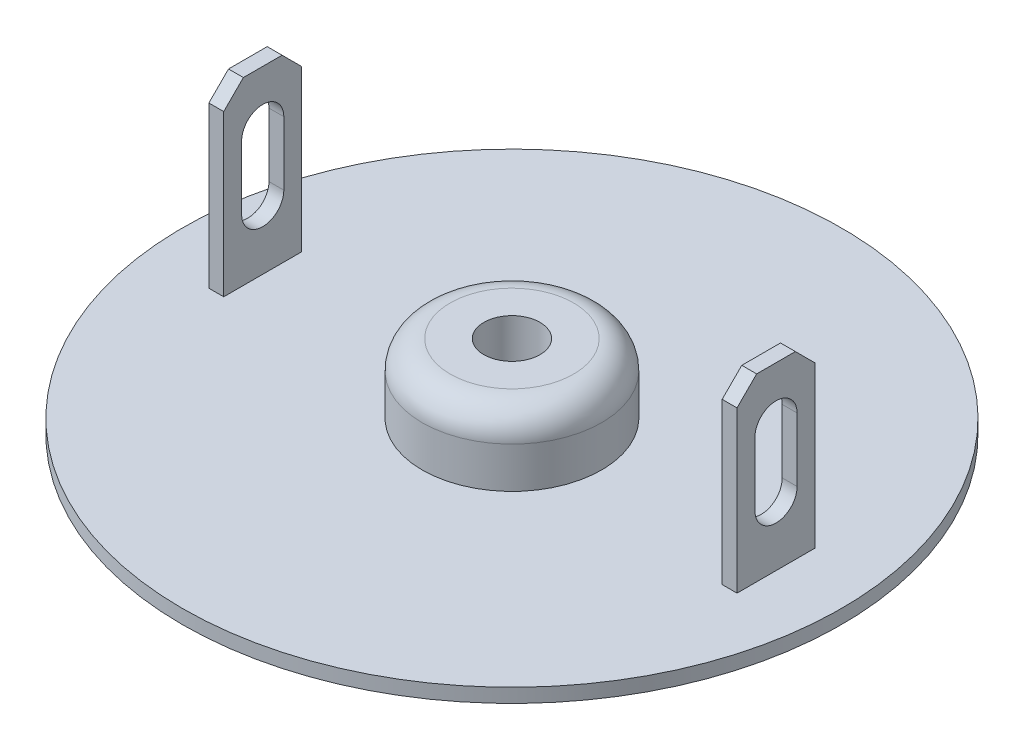
from build123d import *

# Parameters (mm, degrees)
SKETCH_1_R                 = 11.75
SKETCH_1_R_2               = 1
EXTRUDE_1_DEPTH            = 0.5
SKETCH_2_W                 = 0.53
SKETCH_2_H                 = 2.78
EXTRUDE_2_DEPTH            = 6.42
CHAMFER_1_SIZE             = 0.7
CUT_EXTRUDE_1_DEPTH        = 0.53
SKETCH_4_W                 = 2.2
SKETCH_4_H                 = 2.46
FILLET_1_R                 = 1
CHAMFER_1_OF_MIRROR_1_SIZE = 0.7


with BuildPart() as part:
    # 草图1 → 凸台-拉伸1 (new body)
    with BuildSketch(Plane(origin=(0, 0, 0), x_dir=(1, 0, 0), z_dir=(0, 1, 0))):
        Circle(SKETCH_1_R)
        Circle(SKETCH_1_R_2, mode=Mode.SUBTRACT)
    extrude(amount=EXTRUDE_1_DEPTH)

    # 草图2 → 凸台-拉伸2 (add)
    with BuildSketch(Plane(origin=(0, 0.5, 0), x_dir=(1, 0, 0), z_dir=(0, 1, 0))):
        with Locations((-9.15, 0)):
            Rectangle(SKETCH_2_W, SKETCH_2_H)
    extrude_2 = extrude(amount=EXTRUDE_2_DEPTH)

    # 倒角1
    chamfer_1_edges = [part.edges().sort_by_distance(p)[0] for p in [
        (-9.15, 6.92, -1.39),
        (-9.15, 6.92, 1.39),
    ]]
    chamfer(chamfer_1_edges, length=CHAMFER_1_SIZE)

    # 草图3 → 切除-拉伸1 (cut)
    with BuildSketch(Plane.ZY.offset(9.415)):
        with BuildLine():
            Line((0.751927557, 4.991992343), (0.751927557, 2.722407652))
            ThreePointArc((0.751927557, 2.722407652), (0, 1.970480095), (-0.751927557, 2.722407652))
            Line((-0.751927557, 2.722407652), (-0.751927557, 4.991992343))
            ThreePointArc((-0.751927557, 4.991992343), (0, 5.7439199), (0.751927557, 4.991992343))
        make_face()
    cut_extrude_1 = extrude(amount=-CUT_EXTRUDE_1_DEPTH, mode=Mode.SUBTRACT)

    # 草图4 → 旋转1 (revolve)
    with BuildSketch(Plane.XY):
        with Locations((-2.1, 1.73)):
            Rectangle(SKETCH_4_W, SKETCH_4_H)
    revolve(axis=Axis((0, 3.495676189, 0), (0, -1, 0)))

    # 圆角1
    fillet_1_edges = [part.edges().sort_by_distance(p)[0] for p in [
        (3.2, 2.96, 0),
    ]]
    fillet(fillet_1_edges, radius=FILLET_1_R)

    # 镜向1: 凸台-拉伸2, 切除-拉伸1 across plane
    add(extrude_2.mirror(Plane(origin=(0, 0, 0), x_dir=(0, 0, 1), z_dir=(1, 0, 0))))
    add(cut_extrude_1.mirror(Plane(origin=(0, 0, 0), x_dir=(0, 0, 1), z_dir=(1, 0, 0))), mode=Mode.SUBTRACT)

    # 倒角1 of 镜向1
    chamfer_1_of_mirror_1_edges = [part.edges().sort_by_distance(p)[0] for p in [
        (9.15, 6.92, -1.39),
        (9.15, 6.92, 1.39),
    ]]
    chamfer(chamfer_1_of_mirror_1_edges, length=CHAMFER_1_OF_MIRROR_1_SIZE)


solid = part.part
